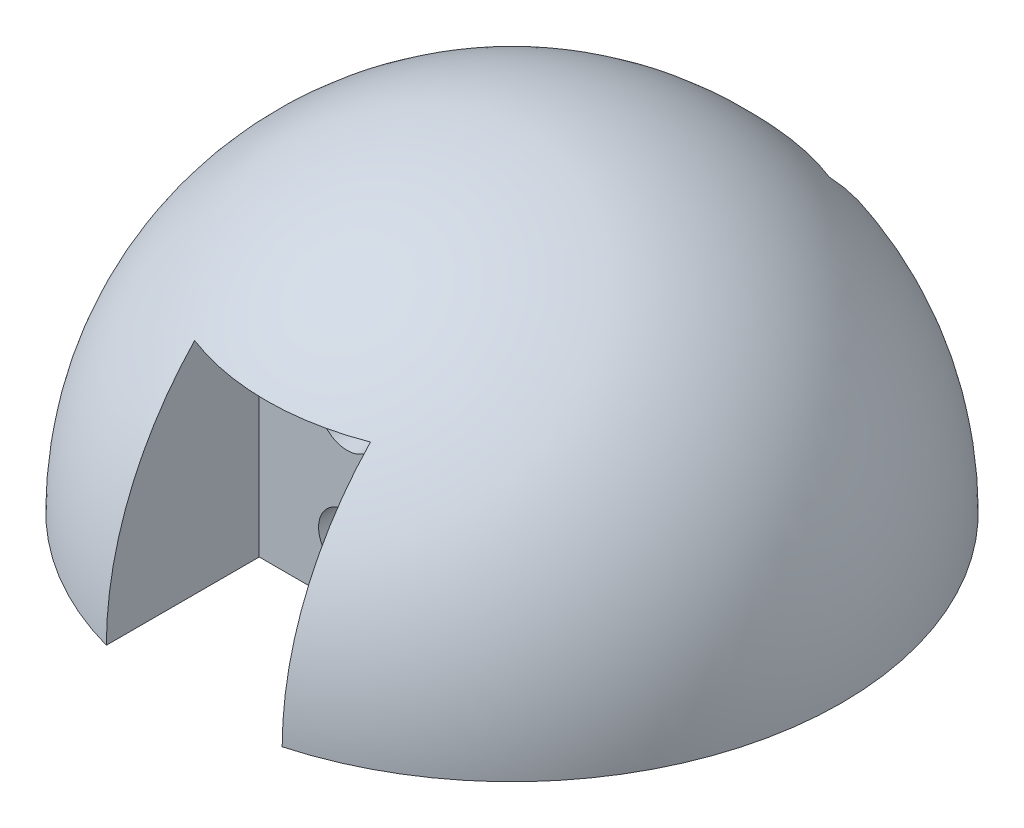
from build123d import *

# Parameters (mm, degrees)
SKETCH3_W           = 20
SKETCH3_H           = 10
CUT_EXTRUDE1_DEPTH  = 20
SKETCH4_R           = 2.6
CUT_EXTRUDE2_DEPTH  = 26
SKETCH7_R           = 2.6
CUT_EXTRUDE4_DEPTH  = 26
SKETCH8_W           = 16
SKETCH8_H           = 20
CUT_EXTRUDE9_DEPTH  = 15
SKETCH6_W           = 16
SKETCH6_H           = 20
CUT_EXTRUDE10_DEPTH = 15


with BuildPart() as part:
    # Sketch2 → Revolve1 (revolve)
    with BuildSketch(Plane.XY):
        with BuildLine():
            Line((-30, 0), (0, 0))
            Line((0, 0), (0, 30))
            ThreePointArc((0, 30), (-21.213203436, 21.213203436), (-30, 0))
        make_face()
    revolve(axis=Axis((0, 0, 0), (0, 1, 0)))

    # Sketch3 → Cut-Extrude1 (cut)
    with BuildSketch(Plane.XZ):
        Rectangle(SKETCH3_W, SKETCH3_H)
    extrude(amount=-CUT_EXTRUDE1_DEPTH, mode=Mode.SUBTRACT)

    # Sketch4 → Cut-Extrude2 (cut, through all)
    with BuildSketch(Plane(origin=(0, 0, 5), x_dir=(-1, 0, 0), z_dir=(0, 0, -1))):
        with Locations((0, 15)):
            Circle(SKETCH4_R)
        with Locations((0, 5.050125629)):
            Circle(SKETCH4_R)
    extrude(amount=-CUT_EXTRUDE2_DEPTH, mode=Mode.SUBTRACT)

    # Sketch7 → Cut-Extrude4 (cut, through all)
    with BuildSketch(Plane.XY.offset(-5)):
        with Locations((0, 5)):
            Circle(SKETCH7_R)
        with Locations((0, 15)):
            Circle(SKETCH7_R)
    extrude(amount=-CUT_EXTRUDE4_DEPTH, mode=Mode.SUBTRACT)

    # Sketch8 → Cut-Extrude9 (cut)
    with BuildSketch(Plane.XY.offset(-30)):
        with Locations((0, 10)):
            Rectangle(SKETCH8_W, SKETCH8_H)
    extrude(amount=CUT_EXTRUDE9_DEPTH, mode=Mode.SUBTRACT)

    # Sketch6 → Cut-Extrude10 (cut)
    with BuildSketch(Plane.XY.offset(30)):
        with Locations((0, 10)):
            Rectangle(SKETCH6_W, SKETCH6_H)
    extrude(amount=-CUT_EXTRUDE10_DEPTH, mode=Mode.SUBTRACT)


solid = part.part
